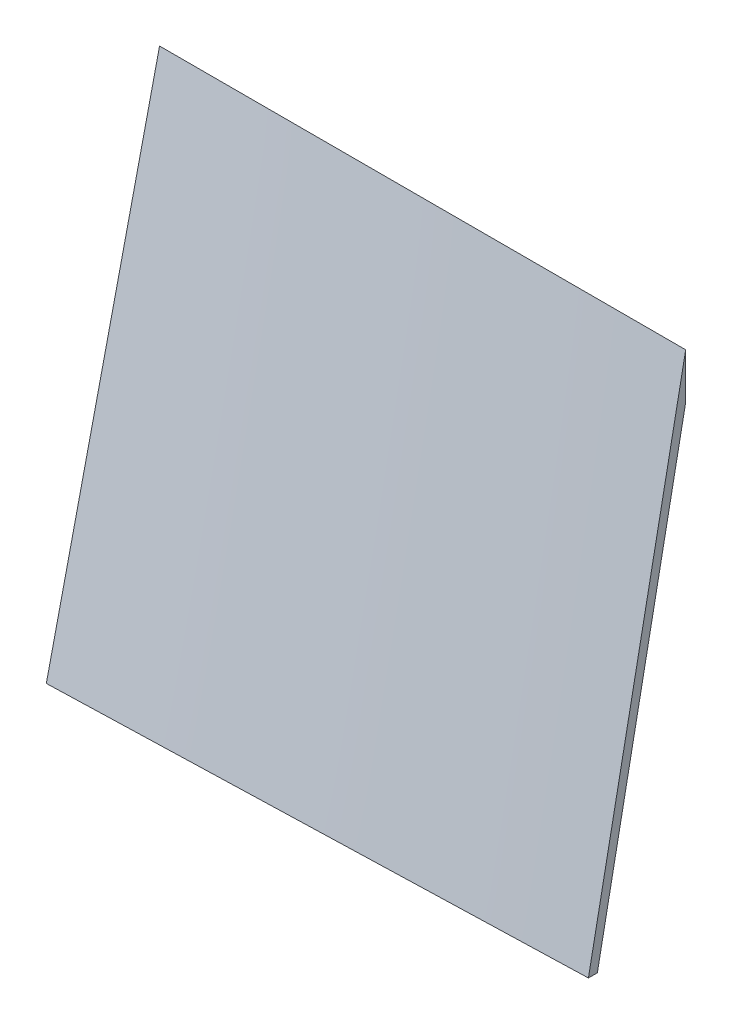
from build123d import *


with BuildPart() as part:
    # Skizze1 → Ausformung1 section 0
    with BuildSketch(Plane(origin=(0, 0, 0), x_dir=(0, 0, -1), z_dir=(1, 0, 0))):
        Polygon((-118.872151806, 0), (0, 520.117445755), (0, 565), (-129.13, 0), align=None)
    # Skizze2 → Ausformung1 section 1
    with BuildSketch(Plane(origin=(600, 0, 0), x_dir=(0, 0, -1), z_dir=(1, 0, 0))):
        Polygon((-100.729116886, 0), (0, 513.090074293), (0, 565), (-110.92, 0), align=None)
    loft()


solid = part.part
